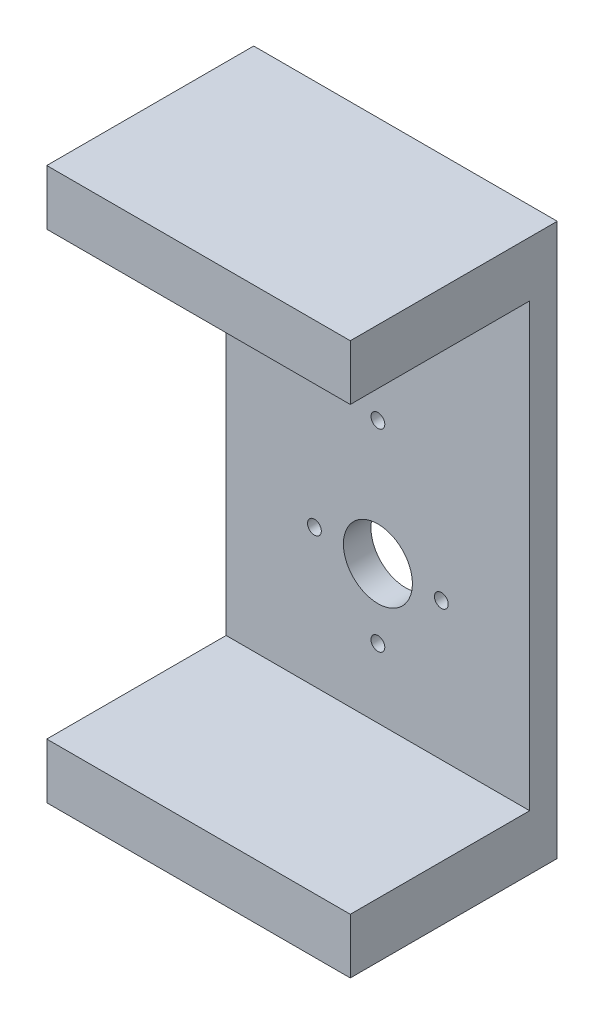
from build123d import *

# Parameters (mm, degrees)
SKETCH1_W           = 200
SKETCH1_H           = 110
BOSS_EXTRUDE1_DEPTH = 10
SKETCH2_W           = 110
SKETCH2_H           = 20
BOSS_EXTRUDE2_DEPTH = 65
SKETCH4_R           = 12.5
CUT_EXTRUDE1_DEPTH  = 76
SKETCH5_R           = 2.5
CUT_EXTRUDE2_DEPTH  = 76
SKETCH3_R           = 2.5
CUT_EXTRUDE3_DEPTH  = 76


with BuildPart() as part:
    # Sketch1 → Boss-Extrude1 (new body)
    with BuildSketch(Plane(origin=(0, 0, 0), x_dir=(0, 1, 0), z_dir=(0, 0, 1))):
        Rectangle(SKETCH1_W, SKETCH1_H)
    extrude(amount=BOSS_EXTRUDE1_DEPTH)

    # Sketch2 → Boss-Extrude2 (add)
    with BuildSketch(Plane.XY.offset(10)):
        with Locations((0, 90)):
            Rectangle(SKETCH2_W, SKETCH2_H)
        with Locations((0, -90)):
            Rectangle(SKETCH2_W, SKETCH2_H)
    extrude(amount=BOSS_EXTRUDE2_DEPTH)

    # Sketch4 → Cut-Extrude1 (cut, through all)
    with BuildSketch(Plane(origin=(0, 0, 0), x_dir=(1, 0, 0), z_dir=(0, 0, -1))):
        with Locations((0, 30)):
            Circle(SKETCH4_R)
    extrude(amount=-CUT_EXTRUDE1_DEPTH, mode=Mode.SUBTRACT)

    # Sketch5 → Cut-Extrude2 (cut, through all)
    with BuildSketch(Plane(origin=(0, 0, 0), x_dir=(1, 0, 0), z_dir=(0, 0, -1))):
        with Locations((23, 30)):
            Circle(SKETCH5_R)
        with Locations((-23, 30)):
            Circle(SKETCH5_R)
    extrude(amount=-CUT_EXTRUDE2_DEPTH, mode=Mode.SUBTRACT)

    # Sketch3 → Cut-Extrude3 (cut, through all)
    with BuildSketch(Plane(origin=(0, 0, 0), x_dir=(1, 0, 0), z_dir=(0, 0, -1))):
        with Locations((0, 55)):
            Circle(SKETCH3_R)
        with Locations((0, -15)):
            Circle(SKETCH3_R)
    extrude(amount=-CUT_EXTRUDE3_DEPTH, mode=Mode.SUBTRACT)


solid = part.part
